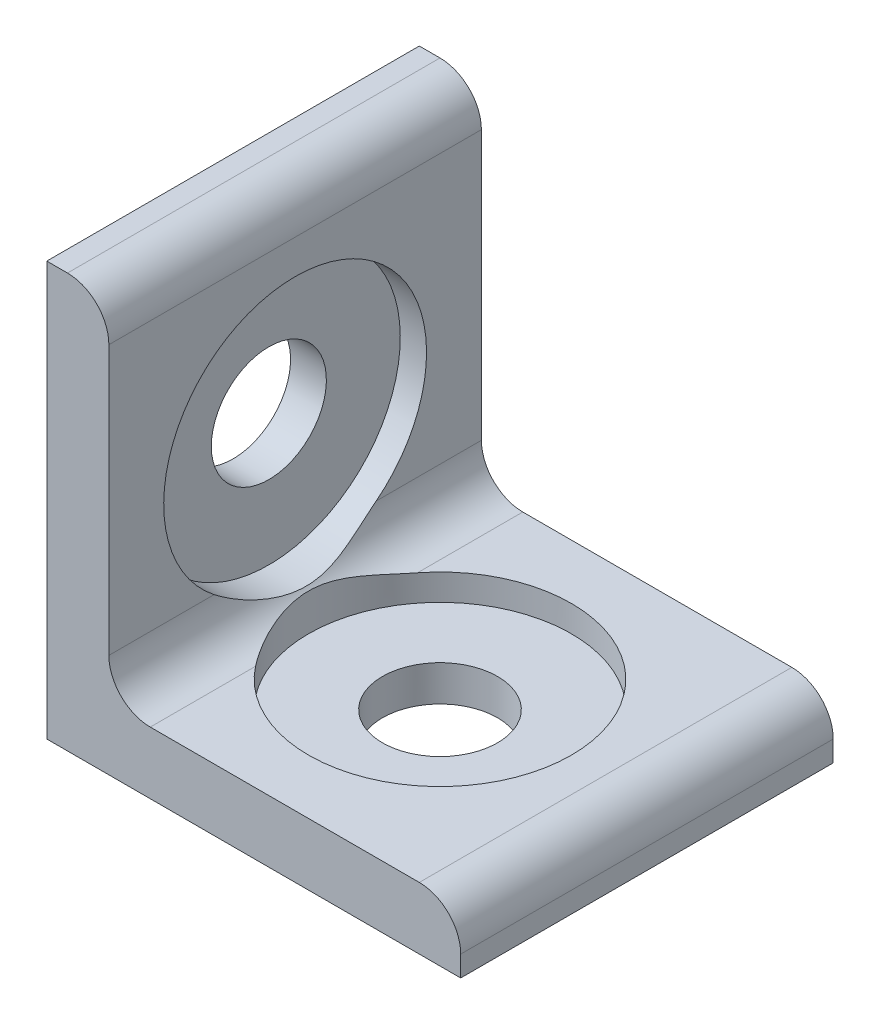
from build123d import *

# Parameters (mm, degrees)
BOSS_EXTRUDE1_DEPTH     = 9
SKETCH2_R               = 2.78
CUT_EXTRUDE1_DEPTH      = 21
SKETCH3_R               = 2.78
CUT_EXTRUDE2_DEPTH      = 21
SKETCH6_R               = 6.35
CUT_EXTRUDE3_DEPTH      = 18
CUT_EXTRUDE3_DEPTH_BACK = 1.27
SKETCH7_R               = 6.35
CUT_EXTRUDE4_DEPTH      = 18
CUT_EXTRUDE4_DEPTH_BACK = 1.27


with BuildPart() as part:
    # Sketch1 → Boss-Extrude1 (new body, symmetric)
    with BuildSketch(Plane.XY):
        with BuildLine():
            Line((0, 0), (20, 0))
            Line((20, 0), (20, 1))
            ThreePointArc((20, 1), (19.414213562, 2.414213562), (18, 3))
            Line((18, 3), (5, 3))
            ThreePointArc((5, 3), (3.585786438, 3.585786438), (3, 5))
            Line((3, 5), (3, 18))
            ThreePointArc((3, 18), (2.414213562, 19.414213562), (1, 20))
            Line((1, 20), (0, 20))
            Line((0, 20), (0, 0))
        make_face()
    extrude(amount=BOSS_EXTRUDE1_DEPTH, both=True)

    # Sketch2 → Cut-Extrude1 (cut, through all)
    with BuildSketch(Plane(origin=(0, 0, 0), x_dir=(-1, 0, 0), z_dir=(0, -1, 0))):
        with Locations((-10, 0)):
            Circle(SKETCH2_R)
    extrude(amount=-CUT_EXTRUDE1_DEPTH, mode=Mode.SUBTRACT)

    # Sketch3 → Cut-Extrude2 (cut, through all)
    with BuildSketch(Plane.ZY):
        with Locations((0, 10)):
            Circle(SKETCH3_R)
    extrude(amount=-CUT_EXTRUDE2_DEPTH, mode=Mode.SUBTRACT)

    # Sketch6 → Cut-Extrude3 (cut, two sides)
    with BuildSketch(Plane(origin=(3, 0, 0), x_dir=(0, 0, -1), z_dir=(1, 0, 0))) as cut_extrude3_sk:
        with Locations((0, 10)):
            Circle(SKETCH6_R)
    extrude(amount=CUT_EXTRUDE3_DEPTH, mode=Mode.SUBTRACT)
    extrude(cut_extrude3_sk.sketch, amount=-CUT_EXTRUDE3_DEPTH_BACK, mode=Mode.SUBTRACT)

    # Sketch7 → Cut-Extrude4 (cut, two sides)
    with BuildSketch(Plane(origin=(0, 3, 0), x_dir=(1, 0, 0), z_dir=(0, 1, 0))) as cut_extrude4_sk:
        with Locations((10, 0)):
            Circle(SKETCH7_R)
    extrude(amount=CUT_EXTRUDE4_DEPTH, mode=Mode.SUBTRACT)
    extrude(cut_extrude4_sk.sketch, amount=-CUT_EXTRUDE4_DEPTH_BACK, mode=Mode.SUBTRACT)


solid = part.part
